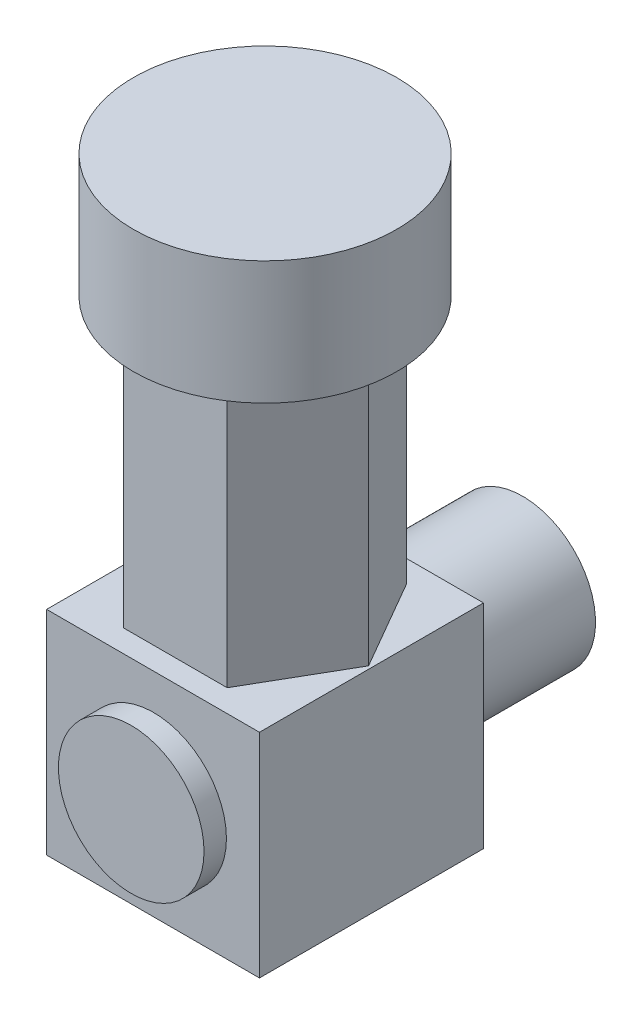
from build123d import *

# Parameters (mm, degrees)
SKETCH1_W           = 19
SKETCH1_H           = 19
BOSS_EXTRUDE1_DEPTH = 20
SKETCH2_R           = 6.5
BOSS_EXTRUDE2_DEPTH = 2
SKETCH3_R           = 6.5
BOSS_EXTRUDE3_DEPTH = 13
BOSS_EXTRUDE4_DEPTH = 35
SKETCH5_R           = 11.75
BOSS_EXTRUDE5_DEPTH = 11


with BuildPart() as part:
    # Sketch1 → Boss-Extrude1 (new body)
    with BuildSketch(Plane.XY):
        with Locations((5.167364017, -0.218619247)):
            Rectangle(SKETCH1_W, SKETCH1_H)
    extrude(amount=BOSS_EXTRUDE1_DEPTH)

    # Sketch2 → Boss-Extrude2 (add)
    with BuildSketch(Plane.XY.offset(20)):
        with Locations((5.218963732, -0.412118181)):
            Circle(SKETCH2_R)
    extrude(amount=BOSS_EXTRUDE2_DEPTH)

    # Sketch3 → Boss-Extrude3 (add)
    with BuildSketch(Plane(origin=(0, 0, 0), x_dir=(-1, 0, 0), z_dir=(0, 0, -1))):
        with Locations((-5.167364017, -0.218619247)):
            Circle(SKETCH3_R)
    extrude(amount=BOSS_EXTRUDE3_DEPTH)

    # Sketch4 → Boss-Extrude4 (add)
    with BuildSketch(Plane(origin=(0, 9.281380753, 0), x_dir=(1, 0, 0), z_dir=(0, 1, 0))):
        Polygon((14.404968324, -10), (9.78616617, -2), (0.548561863, -2), (-4.07024029, -10), (0.548561863, -18), (9.78616617, -18), align=None)
    extrude(amount=BOSS_EXTRUDE4_DEPTH)

    # Sketch5 → Boss-Extrude5 (add)
    with BuildSketch(Plane(origin=(0, 44.281380753, 0), x_dir=(1, 0, 0), z_dir=(0, 1, 0))):
        with Locations((5.167364017, -10)):
            Circle(SKETCH5_R)
    extrude(amount=-BOSS_EXTRUDE5_DEPTH)


solid = part.part
